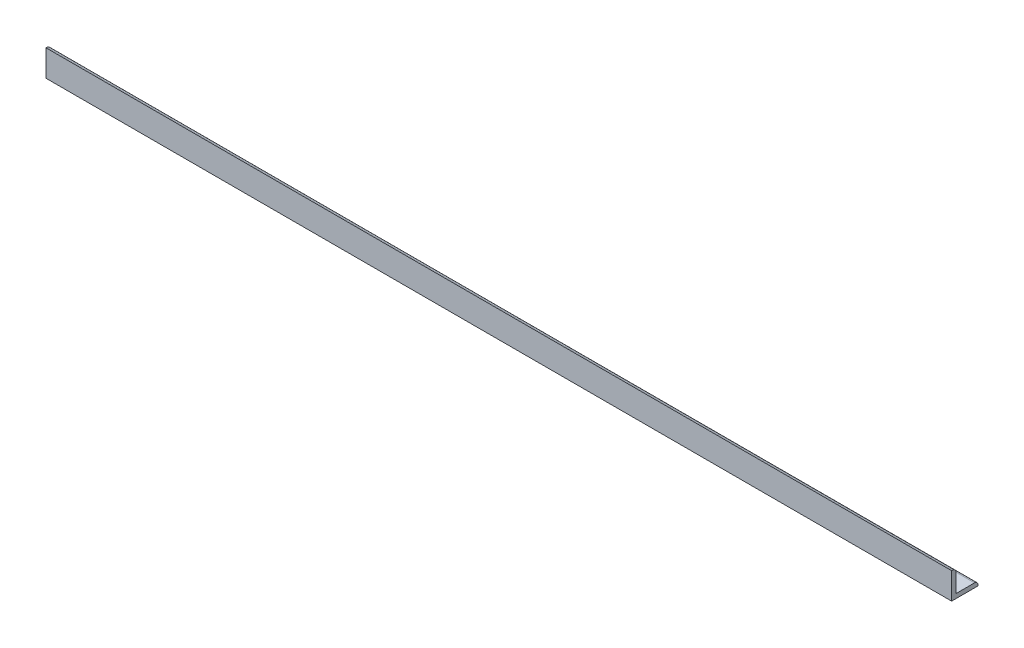
from build123d import *

# Parameters (mm, degrees)
BOSS_EXTRUDE1_DEPTH = 654.07286
CUT_EXTRUDE1_REACH  = 5.175
SKETCH2_R           = 2.54


with BuildPart() as part:
    # Sketch1 → Boss-Extrude1 (new body)
    with BuildSketch(Plane(origin=(0, 0, 0), x_dir=(0, 0, -1), z_dir=(1, 0, 0))):
        with BuildLine():
            Line((3.175, 3.175), (16.51, 3.175))
            ThreePointArc((16.51, 3.175), (18.306051224, 2.431051224), (19.05, 0.635))
            Line((19.05, 0.635), (19.05, 0))
            Line((19.05, 0), (0, 0))
            Line((0, 0), (0, 19.05))
            Line((0, 19.05), (0.635, 19.05))
            ThreePointArc((0.635, 19.05), (2.431051224, 18.306051224), (3.175, 16.51))
            Line((3.175, 16.51), (3.175, 3.175))
        make_face()
    extrude(amount=BOSS_EXTRUDE1_DEPTH)

    # Sketch2 → Cut-Extrude1 (cut, up to next)
    with BuildSketch(Plane(origin=(0, 3.175, 0), x_dir=(1, 0, 0), z_dir=(0, 1, 0)), mode=Mode.PRIVATE) as cut_extrude1_sk1:
        with Locations((641.37286, 9.8425)):
            Circle(SKETCH2_R)
    cut_extrude1_tool1 = extrude(cut_extrude1_sk1.sketch, amount=-CUT_EXTRUDE1_REACH, mode=Mode.PRIVATE) & part.part
    add(cut_extrude1_tool1.solids().sort_by_distance((641.37286, 3.175, -9.8425))[0], mode=Mode.SUBTRACT)
    # Sketch2 → Cut-Extrude1 (cut, up to next)
    with BuildSketch(Plane(origin=(0, 3.175, 0), x_dir=(1, 0, 0), z_dir=(0, 1, 0)), mode=Mode.PRIVATE) as cut_extrude1_sk2:
        with Locations((12.7, 9.8425)):
            Circle(SKETCH2_R)
    cut_extrude1_tool2 = extrude(cut_extrude1_sk2.sketch, amount=-CUT_EXTRUDE1_REACH, mode=Mode.PRIVATE) & part.part
    add(cut_extrude1_tool2.solids().sort_by_distance((12.7, 3.175, -9.8425))[0], mode=Mode.SUBTRACT)


solid = part.part
